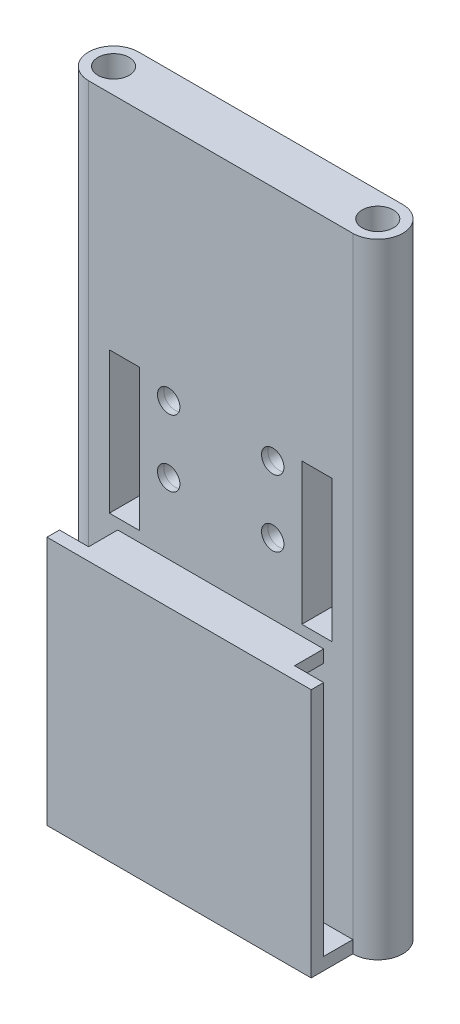
from build123d import *

# Parameters (mm, degrees)
SKETCH1_R            = 3.75
BOSS_EXTRUDE1_DEPTH  = 150
LPATTERN1_COUNT      = 2
LPATTERN1_PITCH      = 76.2
LPATTERN1_COUNT_DIR2 = 2
LPATTERN1_PITCH_DIR2 = 25.4
LPATTERN2_COUNT      = 2
LPATTERN2_PITCH      = 14
LPATTERN2_COUNT_DIR2 = 2
LPATTERN2_PITCH_DIR2 = 31.5
LPATTERN3_COUNT      = 2
LPATTERN3_PITCH      = 16
LPATTERN3_COUNT_DIR2 = 2
LPATTERN3_PITCH_DIR2 = 25
SKETCH6_W            = 63.5
SKETCH6_H            = 60
BOSS_EXTRUDE2_DEPTH  = 10
CUT_EXTRUDE1_DEPTH   = 7
SKETCH8_W            = 7.25
SKETCH8_H            = 34
CUT_EXTRUDE2_DEPTH   = 13


with BuildPart() as part:
    # Sketch1 → Boss-Extrude1 (new body)
    with BuildSketch(Plane(origin=(0, 0, 0), x_dir=(1, 0, 0), z_dir=(0, 1, 0))):
        with BuildLine():
            ThreePointArc((-31.75, -6), (-37.75, 0), (-31.75, 6))
            Line((-31.75, 6), (0, 6))
            Line((0, 6), (0, -6))
            Line((0, -6), (-31.75, -6))
        make_face()
        with Locations((-31.75, 0)):
            Circle(SKETCH1_R, mode=Mode.SUBTRACT)
    boss_extrude1 = extrude(amount=BOSS_EXTRUDE1_DEPTH)

    # Mirror1: Boss-Extrude1 across plane
    add(boss_extrude1.mirror(Plane(origin=(0, 150, 0), x_dir=(0, 0, 1), z_dir=(-1, 0, 0))))

    # Sketch2 → Cut-Revolve1 (revolve, cut)
    with BuildSketch(Plane(origin=(12.7, 0, -12.7), x_dir=(0, 0, 1), z_dir=(-1, 0, 0))):
        Polygon((6.2, 65), (15.599823137, 65), (15.599823137, 62.75), (11.59988209, 62.771716936), (8.19988209, 62.321716936), (6.2, 62.3), align=None)
    cut_revolve1 = revolve(axis=Axis((12.7, 65, -6.5), (0, 0, 1)), mode=Mode.SUBTRACT)

    # LPattern1: Cut-Revolve1 2 × 2
    with Locations(*[(-j * LPATTERN1_PITCH_DIR2, i * LPATTERN1_PITCH, 0) for i in range(LPATTERN1_COUNT) for j in range(LPATTERN1_COUNT_DIR2) if (i, j) != (0, 0)]):
        add(cut_revolve1, mode=Mode.SUBTRACT)

    # Sketch3 → Cut-Revolve2 (revolve, cut)
    with BuildSketch(Plane(origin=(15.75, 0, 3.05), x_dir=(0, 0, 1), z_dir=(-1, 0, 0))):
        Polygon((-9.55, 20), (-0.150176863, 20), (-0.150176863, 17.75), (-4.15011791, 17.771716936), (-7.55011791, 17.321716936), (-9.55, 17.3), align=None)
    cut_revolve2 = revolve(axis=Axis((15.75, 20, -6.5), (0, 0, 1)), mode=Mode.SUBTRACT)

    # LPattern2: Cut-Revolve2 2 × 2
    with Locations(*[(-j * LPATTERN2_PITCH_DIR2, i * LPATTERN2_PITCH, 0) for i in range(LPATTERN2_COUNT) for j in range(LPATTERN2_COUNT_DIR2) if (i, j) != (0, 0)]):
        add(cut_revolve2, mode=Mode.SUBTRACT)

    # Sketch4 → Cut-Revolve3 (revolve, cut)
    with BuildSketch(Plane(origin=(12.5, 0, 15.55), x_dir=(0, 0, 1), z_dir=(-1, 0, 0))):
        Polygon((-9.05, 77), (-18.449823137, 77), (-18.449823137, 79.25), (-14.44988209, 79.228283064), (-11.04988209, 79.678283064), (-9.05, 79.7), align=None)
    cut_revolve3 = revolve(axis=Axis((12.5, 77, 6.5), (0, 0, -1)), mode=Mode.SUBTRACT)

    # LPattern3: Cut-Revolve3 2 × 2
    with Locations(*[(-j * LPATTERN3_PITCH_DIR2, i * LPATTERN3_PITCH, 0) for i in range(LPATTERN3_COUNT) for j in range(LPATTERN3_COUNT_DIR2) if (i, j) != (0, 0)]):
        add(cut_revolve3, mode=Mode.SUBTRACT)

    # Sketch6 → Boss-Extrude2 (add)
    with BuildSketch(Plane.XY.offset(6)):
        with Locations((0, 30)):
            Rectangle(SKETCH6_W, SKETCH6_H)
    extrude(amount=BOSS_EXTRUDE2_DEPTH)

    # Sketch7 → Cut-Extrude1 (cut)
    with BuildSketch(Plane.XY.offset(6)):
        Polygon((-2, 3), (-31.75, 3), (-31.75, 57), (-31.75, 60), (-24.75, 60), (-24.75, 57), (-2, 57), align=None)
    cut_extrude1 = extrude(amount=CUT_EXTRUDE1_DEPTH, mode=Mode.SUBTRACT)

    # Mirror2: Cut-Extrude1 across plane
    add(cut_extrude1.mirror(Plane(origin=(0, 0, 0), x_dir=(0, 0, 1), z_dir=(1, 0, 0))), mode=Mode.SUBTRACT)

    # Sketch8 → Cut-Extrude2 (cut, through all)
    with BuildSketch(Plane.XY.offset(6)):
        with Locations((-23.125, 79.5)):
            Rectangle(SKETCH8_W, SKETCH8_H)
    cut_extrude2 = extrude(amount=-CUT_EXTRUDE2_DEPTH, mode=Mode.SUBTRACT)

    # Mirror3: Cut-Extrude2 across plane
    add(cut_extrude2.mirror(Plane(origin=(0, 0, 0), x_dir=(0, 0, 1), z_dir=(1, 0, 0))), mode=Mode.SUBTRACT)


solid = part.part
